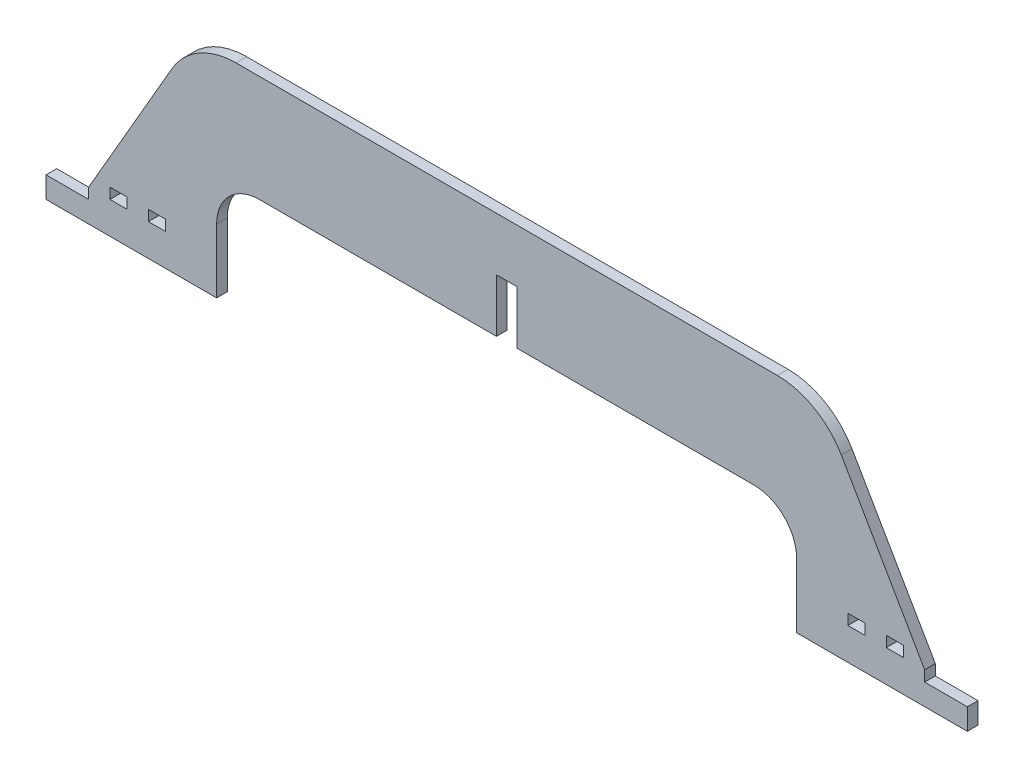
from build123d import *

# Parameters (mm, degrees)
EXTRUDE_1_DEPTH     = 5
CUT_EXTRUDE_1_REACH = 7
EXTRUDE_2_DEPTH     = 5
CUT_EXTRUDE_2_REACH = 7
SKETCH_4_W          = 9.6
SKETCH_4_H          = 50
CUT_EXTRUDE_3_REACH = 7
SKETCH_5_W          = 8
SKETCH_5_H          = 5


with BuildPart() as part:
    # 草图1 → 凸台-拉伸1 (new body)
    with BuildSketch(Plane.XY):
        Polygon((-216, 0), (-216, 10), (-196, 10), (-196, 15), (-146.925227119, 100), (146.925227119, 100), (196, 15), (196, 10), (216, 10), (216, 0), (136, 0), (136, 50), (-136, 50), (-136, 0), align=None)
    extrude(amount=EXTRUDE_1_DEPTH)

    # 草图2 → 切除-拉伸1 (cut, up to next)
    with BuildSketch(Plane.XY.offset(5), mode=Mode.PRIVATE) as cut_extrude_1_sk1:
        with BuildLine():
            Line((-146.925227119, 100), (-126.925227119, 100))
            ThreePointArc((-126.925227119, 100), (-144.245735195, 95.358983849), (-156.925227119, 82.679491924))
            Line((-156.925227119, 82.679491924), (-146.925227119, 100))
        make_face()
    cut_extrude_1_tool1 = extrude(cut_extrude_1_sk1.sketch, amount=-CUT_EXTRUDE_1_REACH, mode=Mode.PRIVATE) & part.part
    add(cut_extrude_1_tool1.solids().sort_by_distance((-144.827064, 96.365874, 5))[0], mode=Mode.SUBTRACT)
    # 草图2 → 切除-拉伸1 (cut, up to next)
    with BuildSketch(Plane.XY.offset(5), mode=Mode.PRIVATE) as cut_extrude_1_sk2:
        with BuildLine():
            Line((146.925227119, 100), (156.925227119, 82.679491924))
            ThreePointArc((156.925227119, 82.679491924), (144.245735195, 95.358983849), (126.925227119, 100))
            Line((126.925227119, 100), (146.925227119, 100))
        make_face()
    cut_extrude_1_tool2 = extrude(cut_extrude_1_sk2.sketch, amount=-CUT_EXTRUDE_1_REACH, mode=Mode.PRIVATE) & part.part
    add(cut_extrude_1_tool2.solids().sort_by_distance((144.827064, 96.365874, 5))[0], mode=Mode.SUBTRACT)

    # 草图3 → 凸台-拉伸2 (add)
    with BuildSketch(Plane.XY.offset(5)):
        with BuildLine():
            Line((-116, 50), (-136, 50))
            Line((-136, 50), (-136, 30))
            ThreePointArc((-136, 30), (-130.142135624, 44.142135624), (-116, 50))
        make_face()
        with BuildLine():
            Line((136, 50), (136, 30))
            ThreePointArc((136, 30), (130.142135624, 44.142135624), (116, 50))
            Line((116, 50), (136, 50))
        make_face()
    extrude(amount=-EXTRUDE_2_DEPTH)

    # 草图4 → 切除-拉伸2 (cut, up to next)
    with BuildSketch(Plane.XY.offset(5), mode=Mode.PRIVATE) as cut_extrude_2_sk1:
        with Locations((0, 50)):
            Rectangle(SKETCH_4_W, SKETCH_4_H)
    cut_extrude_2_tool1 = extrude(cut_extrude_2_sk1.sketch, amount=-CUT_EXTRUDE_2_REACH, mode=Mode.PRIVATE) & part.part
    add(cut_extrude_2_tool1.solids().sort_by_distance((0, 50, 5))[0], mode=Mode.SUBTRACT)

    # 草图5 → 切除-拉伸3 (cut, up to next)
    with BuildSketch(Plane.XY.offset(5), mode=Mode.PRIVATE) as cut_extrude_3_sk1:
        with Locations((-182, 17.5)):
            Rectangle(SKETCH_5_W, SKETCH_5_H)
    cut_extrude_3_tool1 = extrude(cut_extrude_3_sk1.sketch, amount=-CUT_EXTRUDE_3_REACH, mode=Mode.PRIVATE) & part.part
    add(cut_extrude_3_tool1.solids().sort_by_distance((-182, 17.5, 5))[0], mode=Mode.SUBTRACT)
    # 草图5 → 切除-拉伸3 (cut, up to next)
    with BuildSketch(Plane.XY.offset(5), mode=Mode.PRIVATE) as cut_extrude_3_sk2:
        with Locations((-164, 17.5)):
            Rectangle(SKETCH_5_W, SKETCH_5_H)
    cut_extrude_3_tool2 = extrude(cut_extrude_3_sk2.sketch, amount=-CUT_EXTRUDE_3_REACH, mode=Mode.PRIVATE) & part.part
    add(cut_extrude_3_tool2.solids().sort_by_distance((-164, 17.5, 5))[0], mode=Mode.SUBTRACT)
    # 草图5 → 切除-拉伸3 (cut, up to next)
    with BuildSketch(Plane.XY.offset(5), mode=Mode.PRIVATE) as cut_extrude_3_sk3:
        with Locations((164, 17.5)):
            Rectangle(SKETCH_5_W, SKETCH_5_H)
    cut_extrude_3_tool3 = extrude(cut_extrude_3_sk3.sketch, amount=-CUT_EXTRUDE_3_REACH, mode=Mode.PRIVATE) & part.part
    add(cut_extrude_3_tool3.solids().sort_by_distance((164, 17.5, 5))[0], mode=Mode.SUBTRACT)
    # 草图5 → 切除-拉伸3 (cut, up to next)
    with BuildSketch(Plane.XY.offset(5), mode=Mode.PRIVATE) as cut_extrude_3_sk4:
        with Locations((182, 17.5)):
            Rectangle(SKETCH_5_W, SKETCH_5_H)
    cut_extrude_3_tool4 = extrude(cut_extrude_3_sk4.sketch, amount=-CUT_EXTRUDE_3_REACH, mode=Mode.PRIVATE) & part.part
    add(cut_extrude_3_tool4.solids().sort_by_distance((182, 17.5, 5))[0], mode=Mode.SUBTRACT)


solid = part.part
